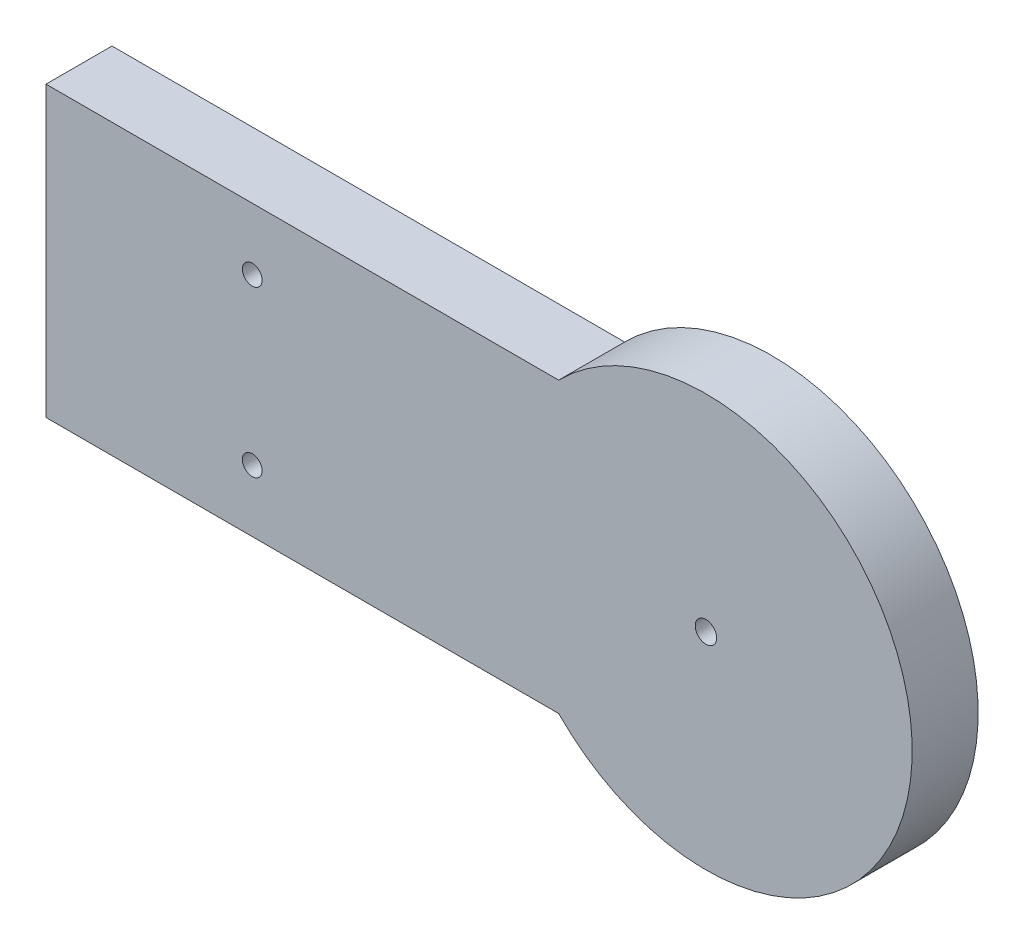
from build123d import *

# Parameters (mm, degrees)
DODANIE_WYCI_GNI_CIE1_DEPTH = 8
OTW_R_POD_RUB_M22_D         = 2.6
SKORUPA1_T                  = -3
DODANIE_WYCI_GNI_CIE2_REACH = 228.526
OTW_R_POD_RUB_M21_D         = 2.6
WYTNIJ_WYCI_GNI_CIE1_REACH  = 228.526
SZKIC7_W                    = 41
SZKIC7_H                    = 21
OTWORY_USTALAJ_CE_8_0MM1_D  = 8
SZKIC18_W                   = 8
SZKIC18_H                   = 6
SZKIC18_W_2                 = 6
SZKIC18_H_2                 = 4
DODANIE_WYCI_GNI_CIE3_DEPTH = 10
SZYK_LINIOWY1_COUNT         = 2
SZYK_LINIOWY1_PITCH         = 50
OTW_R_POD_RUB_M24_D         = 2.4


with BuildPart() as part:
    # Szkic1 → Dodanie-wyciągnięcie1 (new body)
    with BuildSketch(Plane.XY):
        with BuildLine():
            Line((17.853571071, 17.5), (182.146428929, 17.5))
            ThreePointArc((182.146428929, 17.5), (225, 0), (182.146428929, -17.5))
            Line((182.146428929, -17.5), (17.853571071, -17.5))
            ThreePointArc((17.853571071, -17.5), (-25, 0), (17.853571071, 17.5))
        make_face()
    extrude(amount=DODANIE_WYCI_GNI_CIE1_DEPTH)

    # Otwór pod śrubę M22 (through all)
    with Locations(Plane(origin=(0, 0, 8), x_dir=(-1, 0, 0), z_dir=(0, 0, 1))):
        with Locations((-200, 0)):
            Hole(OTW_R_POD_RUB_M22_D / 2)

    # Skorupa1
    skorupa1_openings = [part.faces().sort_by_distance(p)[0] for p in [
        (99.943079522, 0, 0),
    ]]
    offset(amount=SKORUPA1_T, openings=skorupa1_openings, kind=Kind.INTERSECTION)

    # Szkic15 → Dodanie-wyciągnięcie2 (add, up to next)
    with BuildSketch(Plane(origin=(0, 0, 0), x_dir=(-1, 0, 0), z_dir=(0, 0, -1)), mode=Mode.PRIVATE) as dodanie_wyci_gni_cie2_sk1:
        with BuildLine():
            Line((-16.545392108, -14.5), (-19.124591499, -14.5))
            ThreePointArc((-19.124591499, -14.5), (-24, 0), (-19.124591499, 14.5))
            Line((-19.124591499, 14.5), (-16.545392108, 14.5))
            ThreePointArc((-16.545392108, 14.5), (-22, 0), (-16.545392108, -14.5))
        make_face()
    dodanie_wyci_gni_cie2_tool1 = extrude(dodanie_wyci_gni_cie2_sk1.sketch, amount=-DODANIE_WYCI_GNI_CIE2_REACH, mode=Mode.PRIVATE) - part.part
    # Szkic15 → Dodanie-wyciągnięcie2 (add, up to next)
    with BuildSketch(Plane(origin=(0, 0, 0), x_dir=(-1, 0, 0), z_dir=(0, 0, -1)), mode=Mode.PRIVATE) as dodanie_wyci_gni_cie2_sk2:
        with BuildLine():
            Line((-180.875408501, -14.5), (-183.454607892, -14.5))
            ThreePointArc((-183.454607892, -14.5), (-178, 0), (-183.454607892, 14.5))
            Line((-183.454607892, 14.5), (-180.875408501, 14.5))
            ThreePointArc((-180.875408501, 14.5), (-176, 0), (-180.875408501, -14.5))
        make_face()
    dodanie_wyci_gni_cie2_tool2 = extrude(dodanie_wyci_gni_cie2_sk2.sketch, amount=-DODANIE_WYCI_GNI_CIE2_REACH, mode=Mode.PRIVATE) - part.part
    add(dodanie_wyci_gni_cie2_tool1.solids().sort_by_distance((17.834992, 14.200572, 0))[0])
    add(dodanie_wyci_gni_cie2_tool2.solids().sort_by_distance((182.165008, -14.200572, 0))[0])

    # Otwór pod śrubę M21 (through all)
    with Locations(Plane.XY.offset(8)):
        with Locations((7.1, 0), (-7.1, 0)):
            Hole(OTW_R_POD_RUB_M21_D / 2)

    # Szkic7 → Wytnij-wyciągnięcie1 (cut, up to next)
    with BuildSketch(Plane(origin=(0, 0, 0), x_dir=(-1, 0, 0), z_dir=(0, 0, -1)), mode=Mode.PRIVATE) as wytnij_wyci_gni_cie1_sk1:
        with Locations((-55, 0)):
            Rectangle(SZKIC7_W, SZKIC7_H)
    wytnij_wyci_gni_cie1_tool1 = extrude(wytnij_wyci_gni_cie1_sk1.sketch, amount=-WYTNIJ_WYCI_GNI_CIE1_REACH, mode=Mode.PRIVATE) & part.part
    add(wytnij_wyci_gni_cie1_tool1.solids().sort_by_distance((55, 0, 0))[0], mode=Mode.SUBTRACT)

    # Otwory ustalające Ø8.0mm1 (through all)
    with Locations(Plane(origin=(0, 0, 8), x_dir=(-1, 0, 0), z_dir=(0, 0, 1))):
        with Locations((0, 0)):
            Hole(OTWORY_USTALAJ_CE_8_0MM1_D / 2)

    # Szkic18 → Dodanie-wyciągnięcie3 (add)
    with BuildSketch(Plane(origin=(50, 0, 0), x_dir=(0, 0, -1), z_dir=(1, 0, 0))):
        with Locations((-4, 20.5)):
            Rectangle(SZKIC18_W, SZKIC18_H)
        with Locations((-4, 20.5)):
            Rectangle(SZKIC18_W_2, SZKIC18_H_2, mode=Mode.SUBTRACT)
    dodanie_wyci_gni_cie3 = extrude(amount=DODANIE_WYCI_GNI_CIE3_DEPTH)

    # Szyk liniowy1: Dodanie-wyciągnięcie3 ×2
    with Locations(*[(i * SZYK_LINIOWY1_PITCH, 0, 0) for i in range(1, SZYK_LINIOWY1_COUNT)]):
        add(dodanie_wyci_gni_cie3)

    # Otwór pod śrubę M24 (through all)
    with Locations(Plane(origin=(0, 0, 5), x_dir=(-1, 0, 0), z_dir=(0, 0, -1))):
        with Locations((-145, -10), (-145, 10), (-95, 10), (-95, -10)):
            Hole(OTW_R_POD_RUB_M24_D / 2)

    # Cięcie powierzchnią1
    split(bisect_by=Plane(origin=(120, 0, 0), x_dir=(0, 0, -1), z_dir=(1, 0, 0)), keep=Keep.TOP)


solid = part.part
